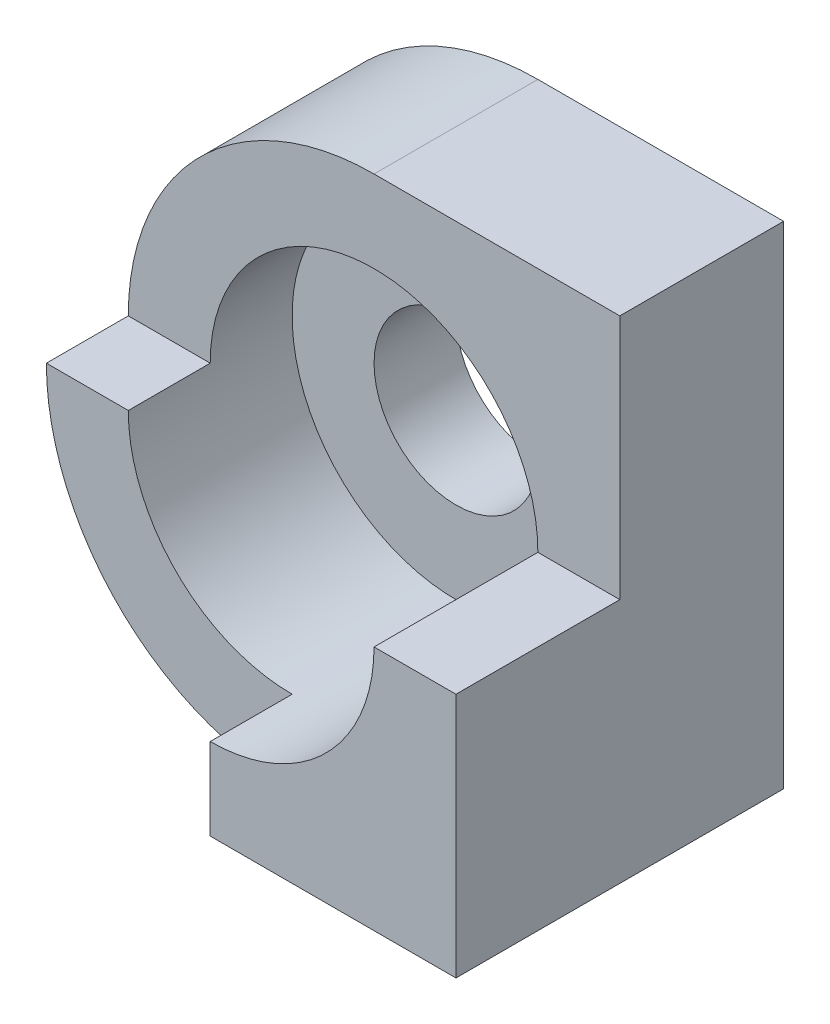
from build123d import *

# Parameters (mm, degrees)
SKETCH1_R           = 1
BOSS_EXTRUDE1_DEPTH = 2
SKETCH2_R           = 2
CUT_EXTRUDE1_DEPTH  = 1
BOSS_EXTRUDE2_DEPTH = 2
BOSS_EXTRUDE3_DEPTH = 1


with BuildPart() as part:
    # Sketch1 → Boss-Extrude1 (new body)
    with BuildSketch(Plane.XY):
        with BuildLine():
            Line((3, 0), (3, 3))
            Line((3, 3), (0, 3))
            ThreePointArc((0, 3), (-3, 0), (0, -3))
            Line((0, -3), (3, -3))
            Line((3, -3), (3, 0))
        make_face()
        Circle(SKETCH1_R, mode=Mode.SUBTRACT)
    extrude(amount=BOSS_EXTRUDE1_DEPTH)

    # Sketch2 → Cut-Extrude1 (cut)
    with BuildSketch(Plane.XY.offset(2)):
        Circle(SKETCH2_R)
    extrude(amount=-CUT_EXTRUDE1_DEPTH, mode=Mode.SUBTRACT)

    # Sketch3 → Boss-Extrude2 (add)
    with BuildSketch(Plane.XY.offset(2)):
        with BuildLine():
            Line((0, -2), (0, -3))
            Line((0, -3), (3, -3))
            Line((3, -3), (3, 0))
            Line((3, 0), (2, 0))
            ThreePointArc((2, 0), (1.414213562, -1.414213562), (0, -2))
        make_face()
    extrude(amount=BOSS_EXTRUDE2_DEPTH)

    # Sketch4 → Boss-Extrude3 (add)
    with BuildSketch(Plane.XY.offset(2)):
        with BuildLine():
            Line((-3, 0), (-2, 0))
            ThreePointArc((-2, 0), (-1.414213562, -1.414213562), (0, -2))
            Line((0, -2), (0, -3))
            ThreePointArc((0, -3), (-2.121320344, -2.121320344), (-3, 0))
        make_face()
    extrude(amount=BOSS_EXTRUDE3_DEPTH)


solid = part.part
